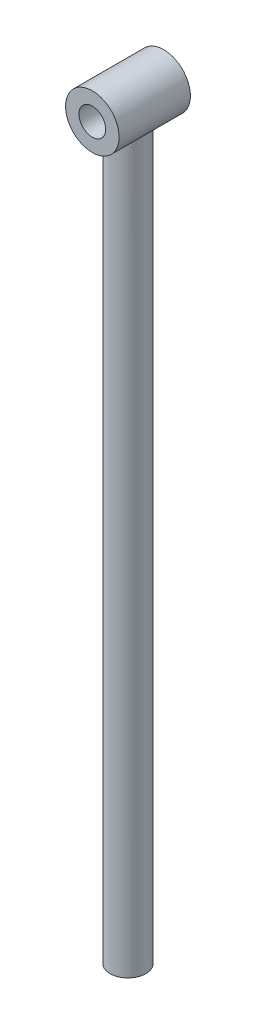
from build123d import *

# Parameters (mm, degrees)
SKETCH1_R           = 20
BOSS_EXTRUDE1_DEPTH = 407.5
SKETCH4_R           = 30
SKETCH4_R_2         = 15
BOSS_EXTRUDE3_DEPTH = 40


with BuildPart() as part:
    # Sketch1 → Boss-Extrude1 (new body, symmetric)
    with BuildSketch(Plane(origin=(0, 0, 0), x_dir=(1, 0, 0), z_dir=(0, 1, 0))):
        Circle(SKETCH1_R)
    extrude(amount=BOSS_EXTRUDE1_DEPTH, both=True)

    # Sketch4 → Boss-Extrude3 (add, symmetric)
    with BuildSketch(Plane.XY):
        with Locations((0, 429.860679775)):
            Circle(SKETCH4_R)
        with Locations((0, 429.860679775)):
            Circle(SKETCH4_R_2, mode=Mode.SUBTRACT)
    extrude(amount=BOSS_EXTRUDE3_DEPTH, both=True)


solid = part.part
